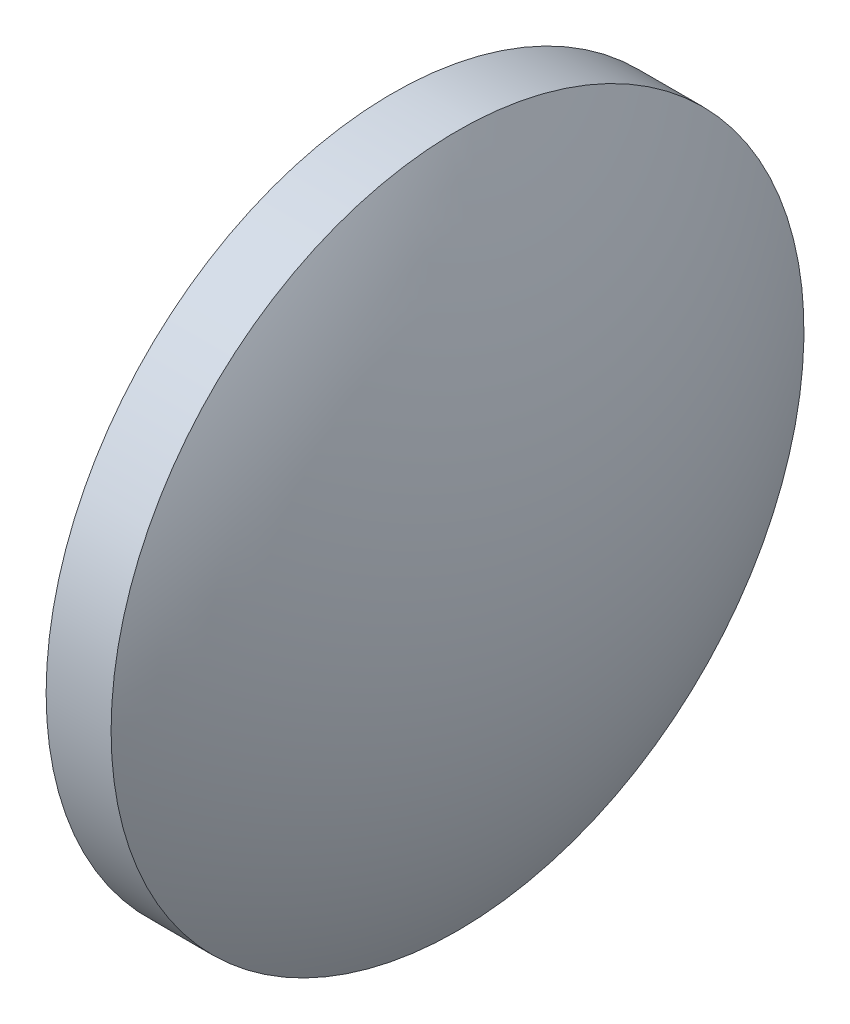
from build123d import *


with BuildPart() as part:
    # 草图1 → 旋转1 (revolve)
    with BuildSketch(Plane.XY, mode=Mode.PRIVATE) as revolve_1_sk:
        with BuildLine():
            Line((393.289652918, 34.86392857), (393.289652918, 42.86392857))
            Line((393.289652918, 42.86392857), (394.789652918, 42.86392857))
            ThreePointArc((394.789652918, 42.86392857), (396.355907761, 38.999445466), (396.889652918, 34.86392857))
            Line((396.889652918, 34.86392857), (393.289652918, 34.86392857))
        make_face()
    revolve(revolve_1_sk.sketch.rotate(Axis((391.366836213, 34.86392857, 0), (1, 0, 0)), 180), axis=Axis((391.366836213, 34.86392857, 0), (1, 0, 0)))  # turned: the seam where the file's is


solid = part.part
